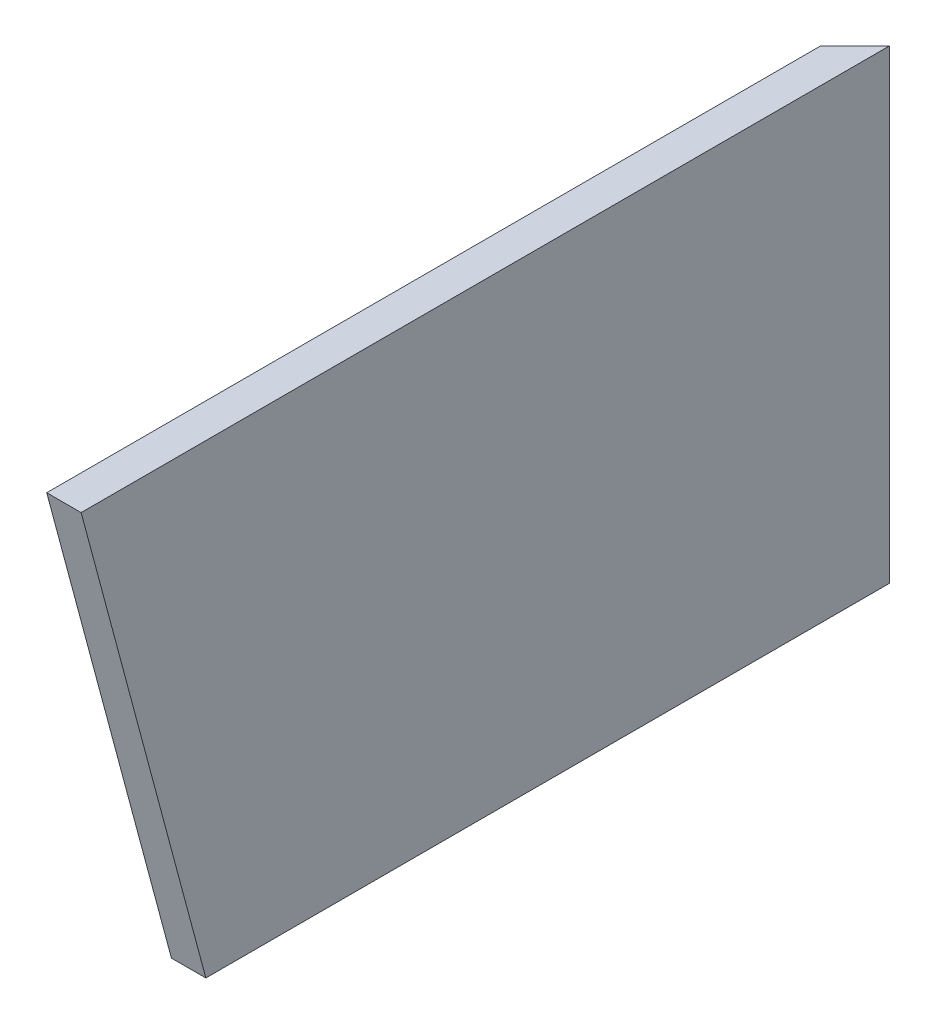
from build123d import *

# Parameters (mm, degrees)
SKETCH2_W           = 12.7
SKETCH2_H           = 171.7294
BOSS_EXTRUDE2_DEPTH = 381
CUT_EXTRUDE1_DEPTH  = 13.7
CUT_EXTRUDE2_DEPTH  = 172.7294


with BuildPart() as part:
    # Sketch2 → Boss-Extrude2 (new body)
    with BuildSketch(Plane.XY):
        with Locations((-6.35, 85.8647)):
            Rectangle(SKETCH2_W, SKETCH2_H)
    extrude(amount=BOSS_EXTRUDE2_DEPTH)

    # Sketch3 → Cut-Extrude1 (cut, through all)
    with BuildSketch(Plane(origin=(0, 0, 0), x_dir=(0, 0, -1), z_dir=(1, 0, 0))):
        Polygon((-252.1712, 0), (-298.185954047, 171.7294), (-381, 171.7294), (-381, 0), align=None)
    extrude(amount=-CUT_EXTRUDE1_DEPTH, mode=Mode.SUBTRACT)

    # Sketch4 → Cut-Extrude2 (cut, through all)
    with BuildSketch(Plane(origin=(0, 171.7294, 0), x_dir=(1, 0, 0), z_dir=(0, 1, 0))):
        Polygon((0, 0), (-12.7, -12.7), (-12.7, 0), align=None)
    extrude(amount=-CUT_EXTRUDE2_DEPTH, mode=Mode.SUBTRACT)


solid = part.part
